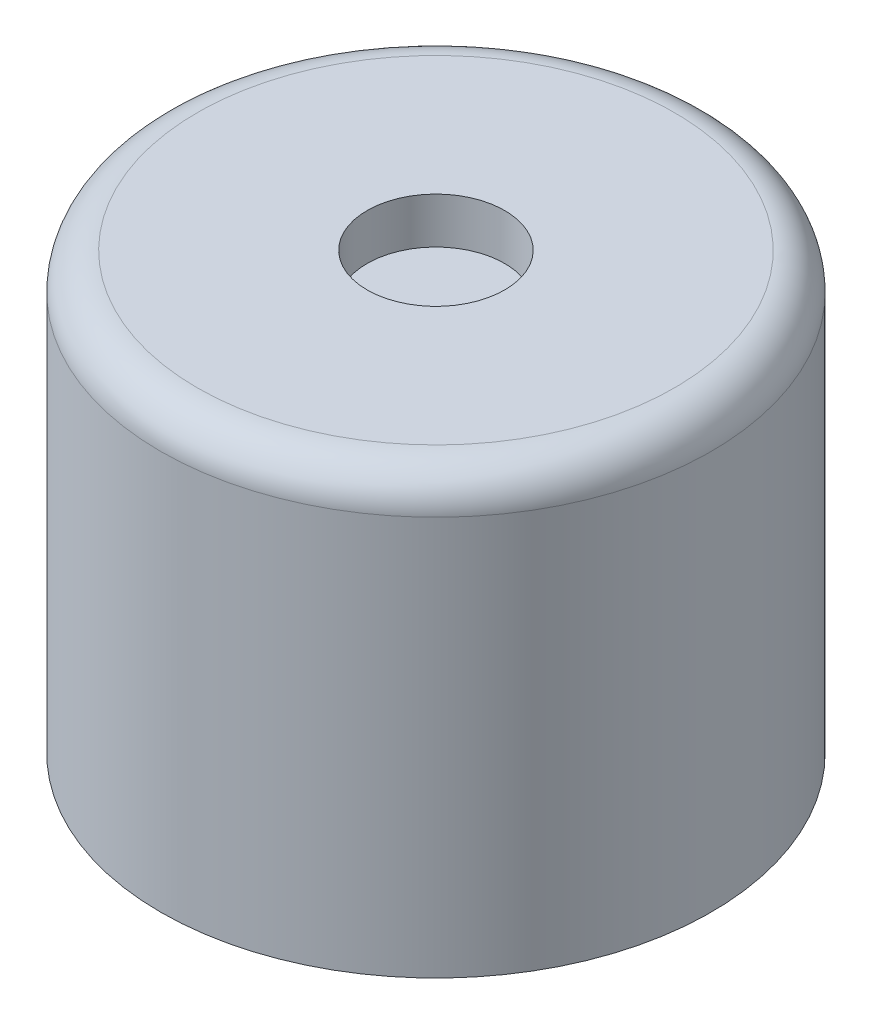
from build123d import *

# Parameters (mm, degrees)
SKETCH1_R           = 6
BOSS_EXTRUDE1_DEPTH = 9.5
SKETCH2_R           = 1.5
CUT_EXTRUDE1_DEPTH  = 1
FILLET1_R           = 0.8


with BuildPart() as part:
    # Sketch1 → Boss-Extrude1 (new body)
    with BuildSketch(Plane(origin=(0, 0, 0), x_dir=(1, 0, 0), z_dir=(0, 1, 0))):
        Circle(SKETCH1_R)
    extrude(amount=BOSS_EXTRUDE1_DEPTH)

    # Sketch2 → Cut-Extrude1 (cut)
    with BuildSketch(Plane(origin=(0, 9.5, 0), x_dir=(1, 0, 0), z_dir=(0, 1, 0))):
        Circle(SKETCH2_R)
    extrude(amount=-CUT_EXTRUDE1_DEPTH, mode=Mode.SUBTRACT)

    # Fillet1
    fillet1_edges = [part.edges().sort_by_distance(p)[0] for p in [
        (-6, 9.5, 0),
    ]]
    fillet(fillet1_edges, radius=FILLET1_R)


solid = part.part
